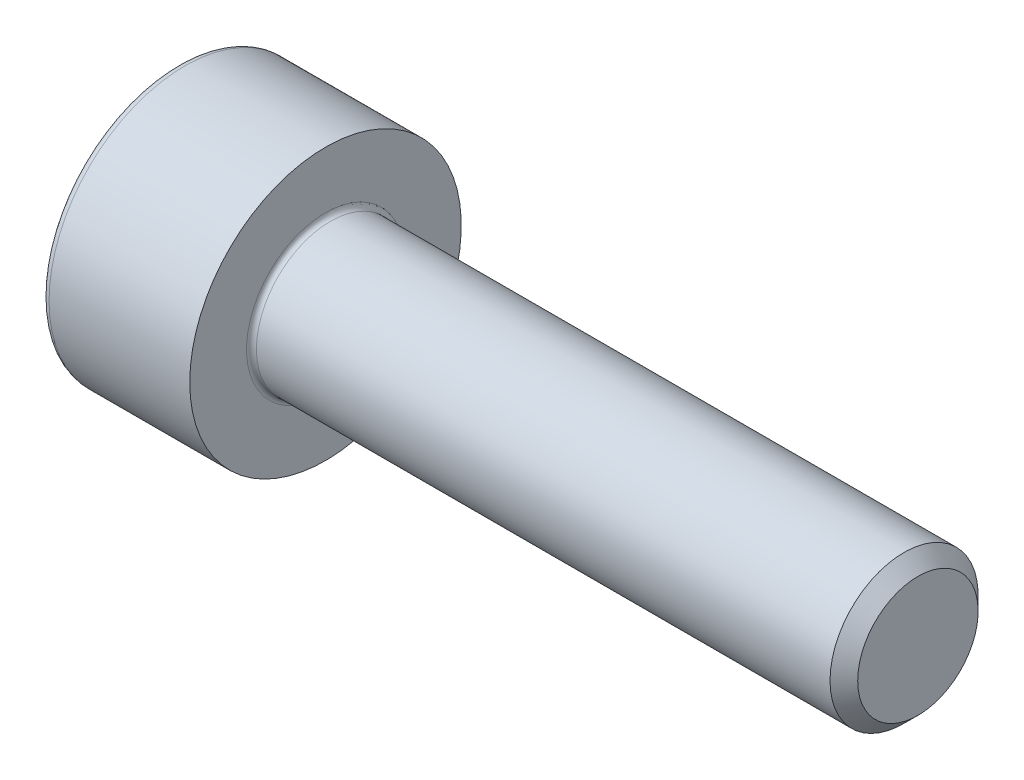
from build123d import *

# Parameters (mm, degrees)
FILLET1_R   = 0.1
FILLET2_R   = 0.15
HEX_2_DEPTH = 1.3


with BuildPart() as part:
    # BodySke → Base-Revolve (revolve)
    with BuildSketch(Plane.XY):
        Polygon((0, 0), (0, 2.75), (3, 2.75), (3, 1.5), (14.7195, 1.5), (15, 1.2195), (15, 0), align=None)
    revolve(axis=Axis((-31.75, 0, 0), (1, 0, 0)))

    # Fillet1
    fillet1_edges = [part.edges().sort_by_distance(p)[0] for p in [
        (3, -1.5, 0),
    ]]
    fillet(fillet1_edges, radius=FILLET1_R)

    # Fillet2
    fillet2_edges = [part.edges().sort_by_distance(p)[0] for p in [
        (0, -2.75, 0),
    ]]
    fillet(fillet2_edges, radius=FILLET2_R)

    # Sketch2 → Hex-PreBroach (revolve, cut)
    with BuildSketch(Plane.XY):
        Polygon((0, 1.28), (1.3, 1.28), (2.039008345, 0), (0, 0), align=None)
    revolve(axis=Axis((0, 0, 0), (1, 0, 0)), mode=Mode.SUBTRACT)

    # Sketch3 → Hex 2 (cut)
    with BuildSketch(Plane(origin=(0, 0, 0), x_dir=(0, 0.5, 0.866025404), z_dir=(-1, 0, 0))):
        Polygon((0.739008345, 1.28), (-0.739008345, 1.28), (-1.478016689, 0), (-0.739008345, -1.28), (0.739008345, -1.28), (1.478016689, 0), align=None)
    extrude(amount=-HEX_2_DEPTH, mode=Mode.SUBTRACT)


solid = part.part
